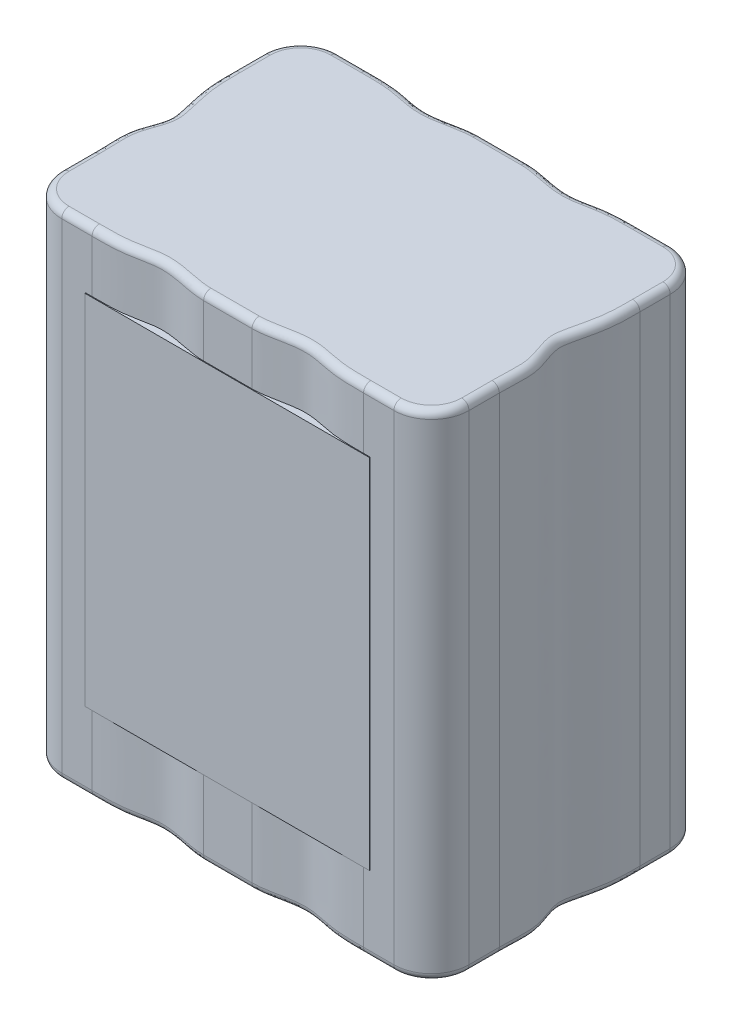
from build123d import *

# Parameters (mm, degrees)
EXTRUDE_1_DEPTH      = 68
FILLET_1_R           = 1
SKETCH_2_W           = 39.111145742
SKETCH_2_H           = 49.191185814
EXTRUDE_2_DEPTH      = 0.1
EXTRUDE_2_DEPTH_BACK = 15


with BuildPart() as part:
    # 草图1 → 凸台-拉伸1 (new body)
    with BuildSketch(Plane(origin=(0, 0, 0), x_dir=(1, 0, 0), z_dir=(0, 1, 0))):
        with BuildLine():
            Line((-22.835738439, 19), (-18.666666667, 19))
            add(Edge.make_bspline(
                [(-18.666666667, 19), (-17.053271728, 19), (-14.227775265, 19.014425815), (-10.118556354, 17.83050022), (-6.552294581, 18.591301736), (-4.314572413, 19), (-3.327607031, 19)],
                knots=[0, 0, 0, 0, 0.301968944, 0.562471385, 0.806411036, 1, 1, 1, 1], degree=3))
            Line((-3.327607031, 19), (3.327607031, 19))
            add(Edge.make_bspline(
                [(18.666666667, 19), (17.053271728, 19), (14.227775265, 19.014425815), (10.118556354, 17.83050022), (6.552294581, 18.591301736), (4.314572413, 19), (3.327607031, 19)],
                knots=[0, 0, 0, 0, 0.301968944, 0.562471385, 0.806411036, 1, 1, 1, 1], degree=3))
            Line((18.666666667, 19), (22.835738439, 19))
            ThreePointArc((22.835738439, 19), (26.487422808, 17.487422808), (28, 13.835738439))
            Line((28, 13.835738439), (28, 9.666666667))
            add(Edge.make_bspline(
                [(28, 9.666666667), (28, 8.513268378), (28.0661587, 5.297760546), (26.745176389, 0.982902541), (26.747621437, -1.095281977), (28.427659785, -4.820000527), (28, -6.767219557), (28, -9.666666667)],
                knots=[0, 0, 0, 0, 0.169964262, 0.367132003, 0.412786754, 0.626511765, 1, 1, 1, 1], degree=3))
            Line((28, -9.666666667), (28, -13.835738439))
            ThreePointArc((28, -13.835738439), (26.487422808, -17.487422808), (22.835738439, -19))
            Line((22.835738439, -19), (18.666666667, -19))
            add(Edge.make_bspline(
                [(18.666666667, -19), (17.053271728, -19), (14.227775265, -19.014425815), (10.118556354, -17.83050022), (6.552294581, -18.591301736), (4.314572413, -19), (3.327607031, -19)],
                knots=[0, 0, 0, 0, 0.301968944, 0.562471385, 0.806411036, 1, 1, 1, 1], degree=3))
            Line((3.327607031, -19), (-3.327607031, -19))
            add(Edge.make_bspline(
                [(-18.666666667, -19), (-17.053271728, -19), (-14.227775265, -19.014425815), (-10.118556354, -17.83050022), (-6.552294581, -18.591301736), (-4.314572413, -19), (-3.327607031, -19)],
                knots=[0, 0, 0, 0, 0.301968944, 0.562471385, 0.806411036, 1, 1, 1, 1], degree=3))
            Line((-18.666666667, -19), (-22.835738439, -19))
            ThreePointArc((-22.835738439, -19), (-26.487422808, -17.487422808), (-28, -13.835738439))
            Line((-28, -13.835738439), (-28, -9.666666667))
            add(Edge.make_bspline(
                [(-28, 9.666666667), (-28, 8.513268378), (-28.0661587, 5.297760546), (-26.745176389, 0.982902541), (-26.747621437, -1.095281977), (-28.427659785, -4.820000527), (-28, -6.767219557), (-28, -9.666666667)],
                knots=[0, 0, 0, 0, 0.169964262, 0.367132003, 0.412786754, 0.626511765, 1, 1, 1, 1], degree=3))
            Line((-28, 9.666666667), (-28, 13.835738439))
            ThreePointArc((-28, 13.835738439), (-26.487422808, 17.487422808), (-22.835738439, 19))
        make_face()
    extrude(amount=EXTRUDE_1_DEPTH)

    # 圆角1
    fillet_1_edges = [part.edges().sort_by_distance(p)[0] for p in [
        (-26.752402197, 68, 0.031357995),
        (-28, 68, 11.751202553),
        (-20.751202553, 0, -19),
        (-10.991471594, 0, -18.230446997),
        (0, 0, -19),
        (10.991471594, 0, -18.230446997),
        (-26.487422808, 68, 17.487422808),
        (20.751202553, 0, -19),
        (26.487422808, 0, -17.487422808),
        (28, 0, -11.751202553),
        (26.752402197, 0, 0.031357995),
        (28, 0, 11.751202553),
        (26.487422808, 0, 17.487422808),
        (20.751202553, 0, 19),
        (10.991471594, 0, 18.230446997),
        (0, 0, 19),
        (-10.991471594, 0, 18.230446997),
        (-20.751202553, 68, 19),
        (-20.751202553, 0, 19),
        (-26.487422808, 0, 17.487422808),
        (-28, 0, 11.751202553),
        (-26.752402197, 0, 0.031357995),
        (-28, 0, -11.751202553),
        (-26.487422808, 0, -17.487422808),
        (-10.991471594, 68, 18.230446997),
        (0, 68, 19),
        (10.991471594, 68, 18.230446997),
        (20.751202553, 68, 19),
        (26.487422808, 68, 17.487422808),
        (28, 68, 11.751202553),
        (-26.487422808, 68, -17.487422808),
        (26.752402197, 68, 0.031357995),
        (28, 68, -11.751202553),
        (26.487422808, 68, -17.487422808),
        (20.751202553, 68, -19),
        (10.991471594, 68, -18.230446997),
        (0, 68, -19),
        (-10.991471594, 68, -18.230446997),
        (-20.751202553, 68, -19),
        (-28, 68, -11.751202553),
    ]]
    fillet(fillet_1_edges, radius=FILLET_1_R)

    # 草图2 → 凸台-拉伸2 (add, two sides)
    with BuildSketch(Plane.XY.offset(19)) as extrude_2_sk:
        with Locations((0, 35.225220048)):
            Rectangle(SKETCH_2_W, SKETCH_2_H)
    extrude(amount=EXTRUDE_2_DEPTH)
    extrude(extrude_2_sk.sketch, amount=-EXTRUDE_2_DEPTH_BACK)


solid = part.part
